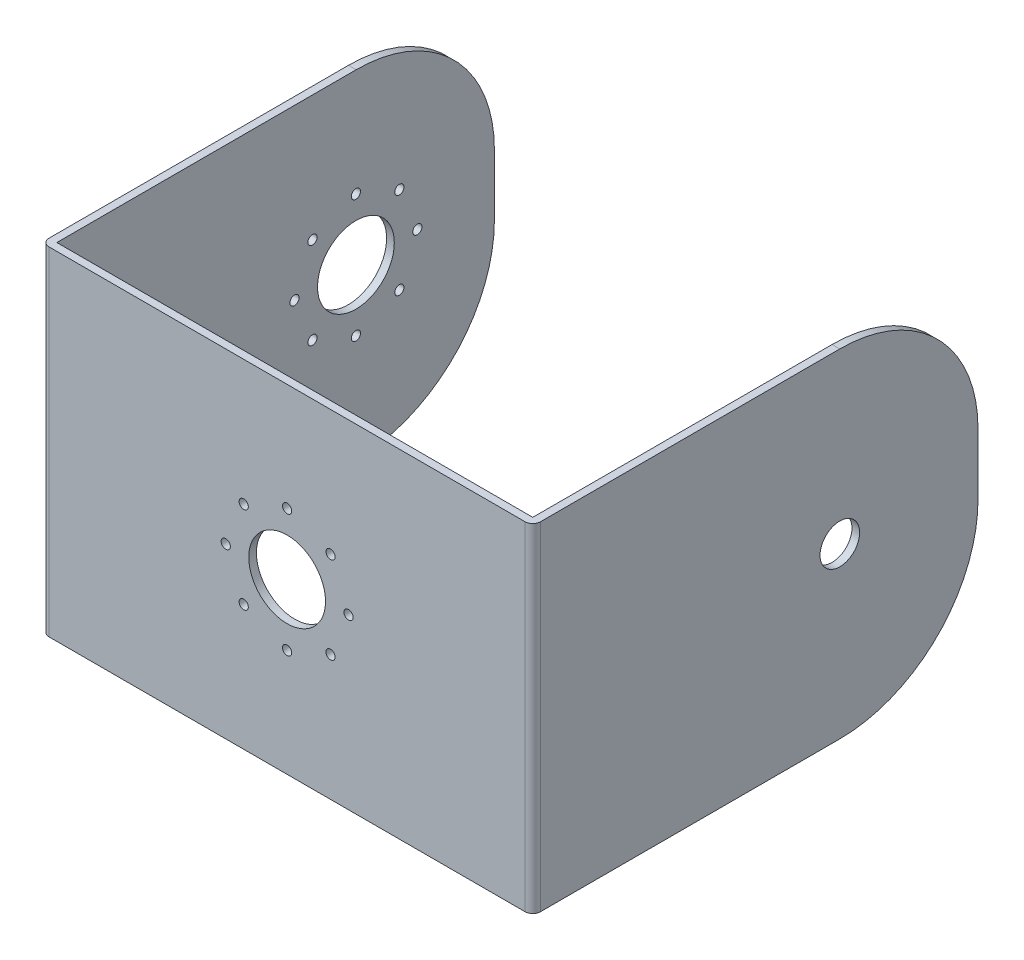
from build123d import *

# Parameters (mm, degrees)
EXTRUDE_THIN1_DEPTH = 44
SKETCH2_R           = 2.58
CUT_EXTRUDE1_DEPTH  = 10
FILLET1_R           = 18
FILLET2_R           = 18
FILLET3_R           = 18
FILLET4_R           = 18
FILLET5_R           = 1
FILLET6_R           = 1
SKETCH11_R          = 5
SKETCH11_R_2        = 0.6
CUT_EXTRUDE2_DEPTH  = 10
SKETCH12_R          = 5
SKETCH12_R_2        = 0.6
CUT_EXTRUDE3_DEPTH  = 10


with BuildPart() as part:
    # Sketch1 → Extrude-Thin1 (new body)
    with BuildSketch(Plane(origin=(0, 0, 0), x_dir=(1, 0, 0), z_dir=(0, 1, 0))):
        Polygon((31, 57), (31, 0), (-31, 0), (-31, 57), (-32, 57), (-32, -1), (32, -1), (32, 57), align=None)
    extrude(amount=EXTRUDE_THIN1_DEPTH)

    # Sketch2 → Cut-Extrude1 (cut)
    with BuildSketch(Plane(origin=(32, 0, 0), x_dir=(0, 0, -1), z_dir=(1, 0, 0))):
        with Locations((39, 22)):
            Circle(SKETCH2_R)
    extrude(amount=-CUT_EXTRUDE1_DEPTH, mode=Mode.SUBTRACT)

    # Fillet1
    fillet1_edges = [part.edges().sort_by_distance(p)[0] for p in [
        (31.5, 0, -57),
    ]]
    fillet(fillet1_edges, radius=FILLET1_R)

    # Fillet2
    fillet2_edges = [part.edges().sort_by_distance(p)[0] for p in [
        (31.5, 44, -57),
    ]]
    fillet(fillet2_edges, radius=FILLET2_R)

    # Fillet3
    fillet3_edges = [part.edges().sort_by_distance(p)[0] for p in [
        (-31.5, 44, -57),
    ]]
    fillet(fillet3_edges, radius=FILLET3_R)

    # Fillet4
    fillet4_edges = [part.edges().sort_by_distance(p)[0] for p in [
        (-31.5, 0, -57),
    ]]
    fillet(fillet4_edges, radius=FILLET4_R)

    # Fillet5
    fillet5_edges = [part.edges().sort_by_distance(p)[0] for p in [
        (-32, 22, 1),
    ]]
    fillet(fillet5_edges, radius=FILLET5_R)

    # Fillet6
    fillet6_edges = [part.edges().sort_by_distance(p)[0] for p in [
        (32, 22, 1),
    ]]
    fillet(fillet6_edges, radius=FILLET6_R)

    # Sketch11 → Cut-Extrude2 (cut)
    with BuildSketch(Plane.ZY.offset(32)):
        with Locations((-38.961003009, 22)):
            Circle(SKETCH11_R)
        with Locations((-38.961003009, 30)):
            Circle(SKETCH11_R_2)
        with Locations((-30.961003009, 22)):
            Circle(SKETCH11_R_2)
        with Locations((-38.961003009, 14)):
            Circle(SKETCH11_R_2)
        with Locations((-46.961003009, 22)):
            Circle(SKETCH11_R_2)
        with Locations((-44.617857259, 27.656854249)):
            Circle(SKETCH11_R_2)
        with Locations((-33.30414876, 27.656854249)):
            Circle(SKETCH11_R_2)
        with Locations((-33.30414876, 16.343145751)):
            Circle(SKETCH11_R_2)
        with Locations((-44.617857259, 16.343145751)):
            Circle(SKETCH11_R_2)
    extrude(amount=-CUT_EXTRUDE2_DEPTH, mode=Mode.SUBTRACT)

    # Sketch12 → Cut-Extrude3 (cut)
    with BuildSketch(Plane.XY.offset(1)):
        with Locations((0, 22)):
            Circle(SKETCH12_R)
        with Locations((0, 30)):
            Circle(SKETCH12_R_2)
        with Locations((5.656854249, 27.656854249)):
            Circle(SKETCH12_R_2)
        with Locations((8, 22)):
            Circle(SKETCH12_R_2)
        with Locations((5.656854249, 16.343145751)):
            Circle(SKETCH12_R_2)
        with Locations((0, 14)):
            Circle(SKETCH12_R_2)
        with Locations((-5.656854249, 16.343145751)):
            Circle(SKETCH12_R_2)
        with Locations((-8, 22)):
            Circle(SKETCH12_R_2)
        with Locations((-5.656854249, 27.656854249)):
            Circle(SKETCH12_R_2)
    extrude(amount=-CUT_EXTRUDE3_DEPTH, mode=Mode.SUBTRACT)


solid = part.part
